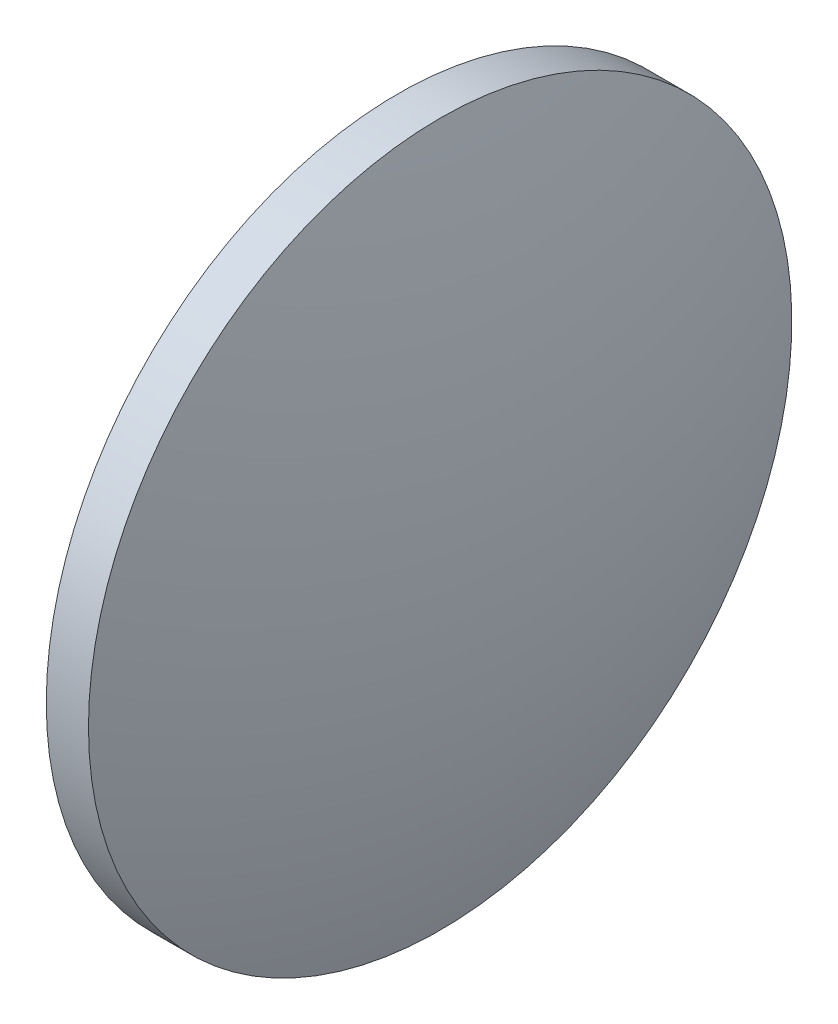
from build123d import *


with BuildPart() as part:
    # 草图1 → 旋转1 (revolve)
    with BuildSketch(Plane.XY):
        with BuildLine():
            Line((491.758071335, 116.237463983), (491.758071335, 141.237463983))
            Line((491.758071335, 141.237463983), (494.758071335, 141.237463983))
            ThreePointArc((494.758071335, 141.237463983), (497.654843697, 128.886346345), (498.628071335, 116.237463983))
            Line((498.628071335, 116.237463983), (491.758071335, 116.237463983))
        make_face()
    revolve(axis=Axis((487.786296046, 116.237463983, 0), (1, 0, 0)))


solid = part.part
